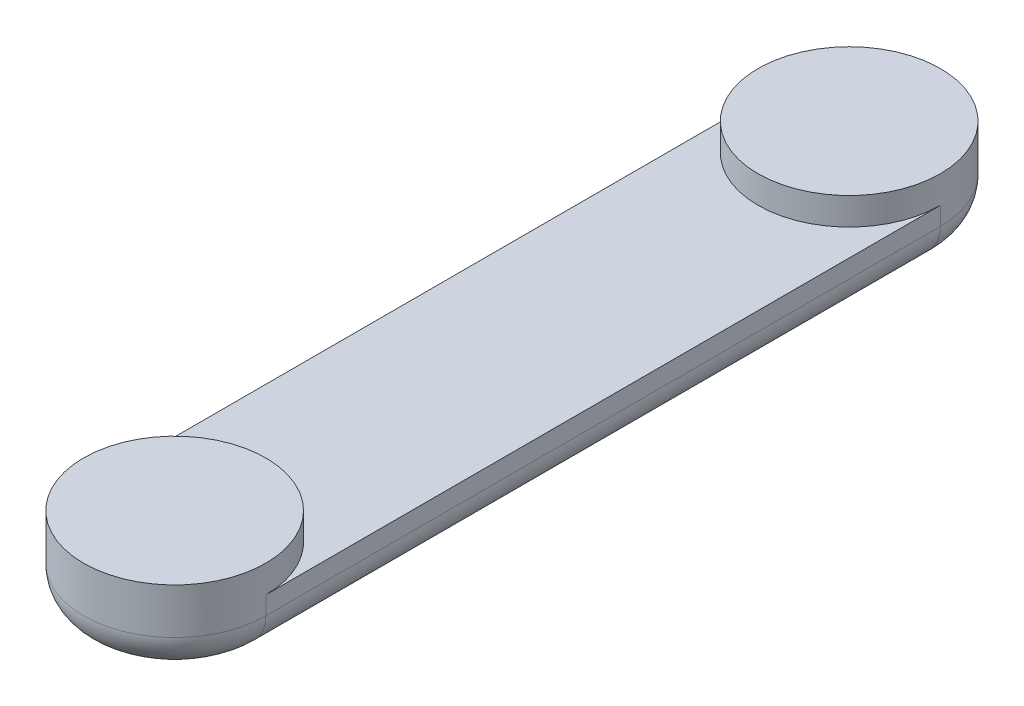
from build123d import *

# Parameters (mm, degrees)
BOSS_EXTRUDE1_DEPTH = 3
SKETCH2_R           = 5
BOSS_EXTRUDE2_DEPTH = 1.5
FILLET1_R           = 2


with BuildPart() as part:
    # Sketch1 → Boss-Extrude1 (new body)
    with BuildSketch(Plane(origin=(0, 0, 0), x_dir=(1, 0, 0), z_dir=(0, 1, 0))):
        with BuildLine():
            Line((-5, 0), (-5, 37))
            ThreePointArc((-5, 37), (0, 42), (5, 37))
            Line((5, 37), (5, 0))
            ThreePointArc((5, 0), (0, -5), (-5, 0))
        make_face()
    extrude(amount=BOSS_EXTRUDE1_DEPTH)

    # Sketch2 → Boss-Extrude2 (add)
    with BuildSketch(Plane(origin=(0, 3, 0), x_dir=(1, 0, 0), z_dir=(0, 1, 0))):
        with BuildLine():
            ThreePointArc((-5, 0), (0, -5), (5, 0))
            ThreePointArc((5, 0), (0, 5), (-5, 0))
        make_face()
        with Locations(Location((0, 37, 0), (0, 0, 180))):
            Circle(SKETCH2_R)
    extrude(amount=BOSS_EXTRUDE2_DEPTH)

    # Fillet1
    fillet1_edges = [part.edges().sort_by_distance(p)[0] for p in [
        (-5, 0, -18.5),
        (0, 0, -42),
        (5, 0, -18.5),
        (0, 0, 5),
    ]]
    fillet(fillet1_edges, radius=FILLET1_R)


solid = part.part
